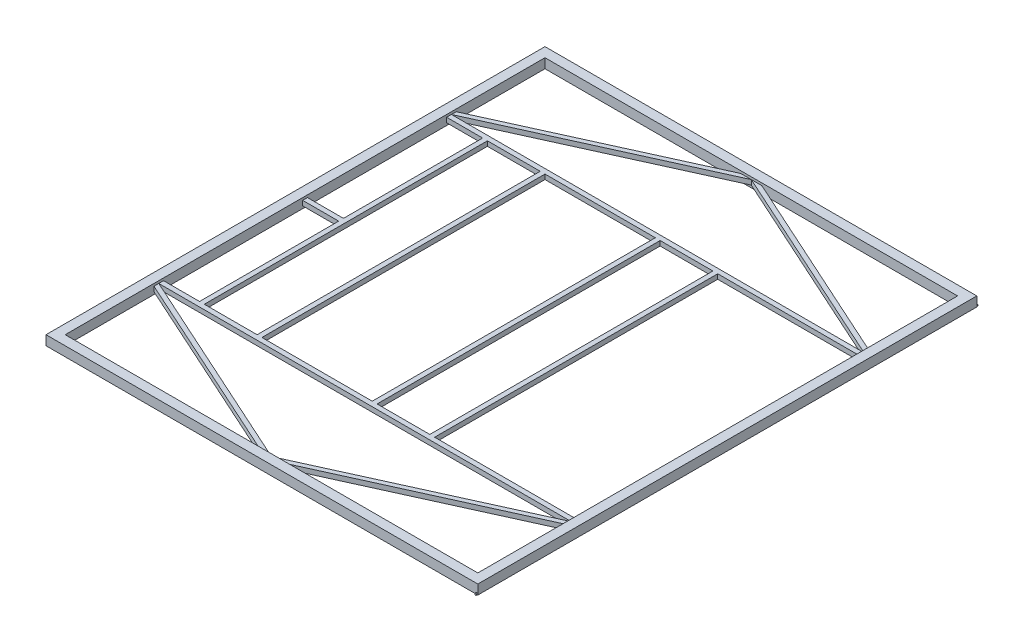
from build123d import *

# Parameters (mm, degrees)
SKETCH1_W           = 50.8
SKETCH1_H           = 50.8
SKETCH1_W_2         = 47.625
SKETCH1_H_2         = 47.625
SKETCH3_R           = 4.7625
BOSS_EXTRUDE1_DEPTH = 6.35
SKETCH4_R           = 4.7625
BOSS_EXTRUDE2_DEPTH = 6.35
SKETCH5_W           = 25.4
SKETCH5_H           = 25.4
SKETCH5_W_2         = 19.05
SKETCH5_H_2         = 19.05
BOSS_EXTRUDE3_DEPTH = 2184.4
SKETCH6_W           = 25.4
SKETCH6_H           = 25.4
SKETCH6_W_2         = 19.05
SKETCH6_H_2         = 19.05
BOSS_EXTRUDE4_DEPTH = 1498.6
SKETCH9_W           = 25.4
SKETCH9_H           = 25.4
SKETCH9_W_2         = 19.05
SKETCH9_H_2         = 19.05
SKETCH7_W           = 25.4
SKETCH7_H           = 25.4
SKETCH7_W_2         = 19.05
SKETCH7_H_2         = 19.05
SKETCH11_W          = 25.4
SKETCH11_H          = 25.4
SKETCH11_W_2        = 19.05
SKETCH11_H_2        = 19.05
BOSS_EXTRUDE5_DEPTH = 190.5


with BuildPart() as part:
    # Sweep1: sweep along a path in Sketch2
    with BuildLine(Plane(origin=(0, 0, 0), x_dir=(1, 0, 0), z_dir=(0, 1, 0))) as sweep1_path:
        Line((-1117.6, 1295.4), (1117.6, 1295.4))
        Line((1117.6, 1295.4), (1117.6, -1295.4))
        Line((1117.6, -1295.4), (-1117.6, -1295.4))
        Line((-1117.6, -1295.4), (-1117.6, 1295.4))
    # Sketch1 → Sweep1 (sweep)
    with BuildSketch(Plane.XY):
        with Locations((1117.6, 0)):
            Rectangle(SKETCH1_W, SKETCH1_H)
        with Locations((1117.6, 0)):
            Rectangle(SKETCH1_W_2, SKETCH1_H_2, mode=Mode.SUBTRACT)
    sweep(path=sweep1_path.line, transition=Transition.RIGHT)

    # Sketch3 → Boss-Extrude1 (add)
    with BuildSketch(Plane(origin=(0, 0, -1320.8), x_dir=(-1, 0, 0), z_dir=(0, 0, -1))):
        with Locations((-1138.2375, -20.6375)):
            Circle(SKETCH3_R)
    extrude(amount=BOSS_EXTRUDE1_DEPTH)

    # Sketch4 → Boss-Extrude2 (add)
    with BuildSketch(Plane.XY.offset(1320.8)):
        with Locations((1138.2375, -20.6375)):
            Circle(SKETCH4_R)
    extrude(amount=BOSS_EXTRUDE2_DEPTH)

    # Sketch5 → Boss-Extrude3 (add)
    with BuildSketch(Plane(origin=(-1092.2, 0, 0), x_dir=(0, 0, -1), z_dir=(1, 0, 0))):
        with Locations((-762, 0)):
            Rectangle(SKETCH5_W, SKETCH5_H)
        with Locations((-762, 0)):
            Rectangle(SKETCH5_W_2, SKETCH5_H_2, mode=Mode.SUBTRACT)
        with Locations((762, 0)):
            Rectangle(SKETCH5_W, SKETCH5_H)
        with Locations((762, 0)):
            Rectangle(SKETCH5_W_2, SKETCH5_H_2, mode=Mode.SUBTRACT)
    extrude(amount=BOSS_EXTRUDE3_DEPTH)

    # Sketch6 → Boss-Extrude4 (add)
    with BuildSketch(Plane(origin=(0, 0, 749.3), x_dir=(-1, 0, 0), z_dir=(0, 0, -1))):
        with Locations((-330.2, 0)):
            Rectangle(SKETCH6_W, SKETCH6_H)
        with Locations((-330.2, 0)):
            Rectangle(SKETCH6_W_2, SKETCH6_H_2, mode=Mode.SUBTRACT)
        with Locations((-25.4, 0)):
            Rectangle(SKETCH6_W, SKETCH6_H)
        with Locations((-25.4, 0)):
            Rectangle(SKETCH6_W_2, SKETCH6_H_2, mode=Mode.SUBTRACT)
        with Locations((584.2, 0)):
            Rectangle(SKETCH6_W, SKETCH6_H)
        with Locations((584.2, 0)):
            Rectangle(SKETCH6_W_2, SKETCH6_H_2, mode=Mode.SUBTRACT)
        with Locations((889, 0)):
            Rectangle(SKETCH6_W, SKETCH6_H)
        with Locations((889, 0)):
            Rectangle(SKETCH6_W_2, SKETCH6_H_2, mode=Mode.SUBTRACT)
    extrude(amount=BOSS_EXTRUDE4_DEPTH)

    # Sweep2: sweep along a path in Sketch10
    with BuildLine(Plane(origin=(0, 25.4, 0), x_dir=(1, 0, 0), z_dir=(0, 1, 0))) as sweep2_path:
        Line((1092.2, -774.7), (0, -1270))
        Line((0, -1270), (-1092.2, -774.7))
    # Sketch9 → Sweep2 (sweep)
    with BuildSketch(Plane.ZY.offset(-1092.2)):
        with Locations((787.4, 0)):
            Rectangle(SKETCH9_W, SKETCH9_H)
        with Locations((787.4, 0)):
            Rectangle(SKETCH9_W_2, SKETCH9_H_2, mode=Mode.SUBTRACT)
    sweep(path=sweep2_path.line, transition=Transition.RIGHT)

    # Sweep4: sweep along a path in Sketch8
    with BuildLine(Plane(origin=(0, 25.4, 0), x_dir=(1, 0, 0), z_dir=(0, 1, 0))) as sweep4_path:
        Line((-1092.2, 774.7), (0, 1270))
        Line((0, 1270), (1092.2, 774.7))
    # Sketch7 → Sweep4 (sweep)
    with BuildSketch(Plane.ZY.offset(-1092.2)):
        with Locations((-787.4, 0)):
            Rectangle(SKETCH7_W, SKETCH7_H)
        with Locations((-787.4, 0)):
            Rectangle(SKETCH7_W_2, SKETCH7_H_2, mode=Mode.SUBTRACT)
    sweep(path=sweep4_path.line, transition=Transition.RIGHT)

    # Sketch11 → Boss-Extrude5 (add)
    with BuildSketch(Plane.ZY.offset(901.7)):
        Rectangle(SKETCH11_W, SKETCH11_H)
        Rectangle(SKETCH11_W_2, SKETCH11_H_2, mode=Mode.SUBTRACT)
    extrude(amount=BOSS_EXTRUDE5_DEPTH)


solid = part.part
